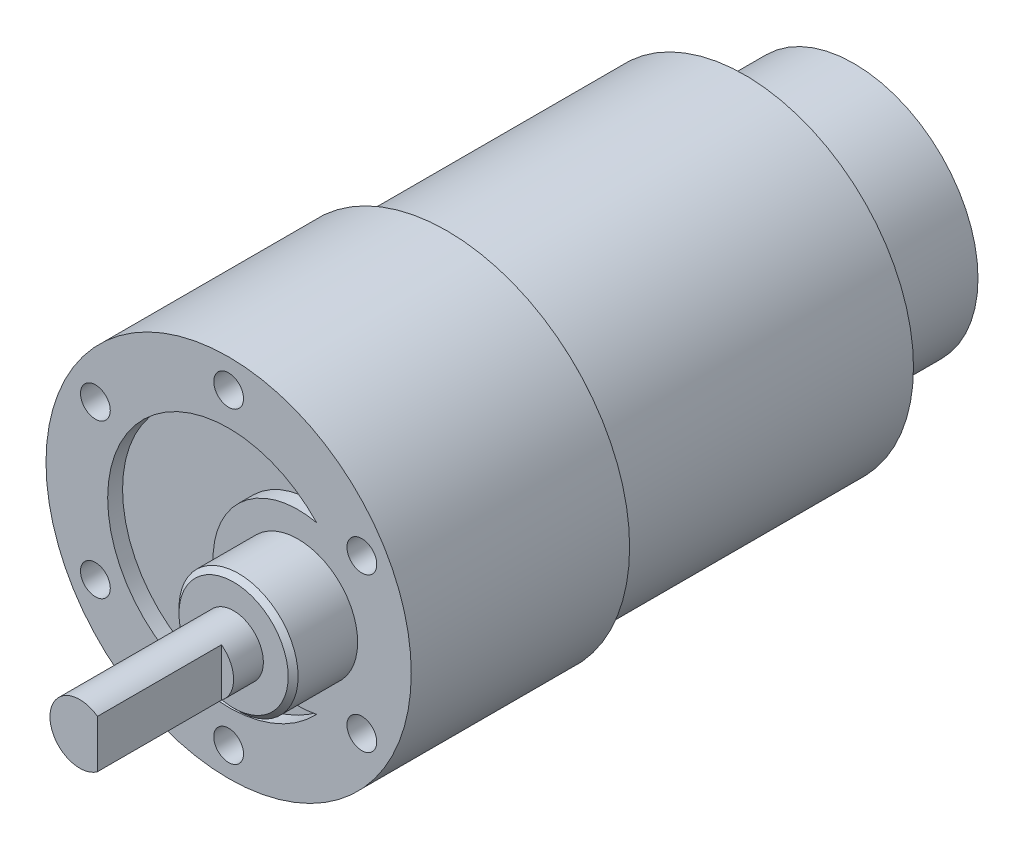
from build123d import *

# Parameters (mm, degrees)
SKETCH1_R           = 17
BOSS_EXTRUDE1_DEPTH = 30
FILLET1_R           = 1
SKETCH2_R           = 18.4
BOSS_EXTRUDE2_DEPTH = 22
SKETCH3_R           = 1.5
CUT_EXTRUDE1_DEPTH  = 3
SKETCH4_R           = 6
BOSS_EXTRUDE3_DEPTH = 6.5
CHAMFER1_SIZE       = 0.5
SKETCH5_R           = 3
BOSS_EXTRUDE4_DEPTH = 15.5
CUT_EXTRUDE3_DEPTH  = 1.5
SKETCH7_R           = 12.5
BOSS_EXTRUDE5_DEPTH = 11
CUT_EXTRUDE4_DEPTH  = 12.5


with BuildPart() as part:
    # Sketch1 → Boss-Extrude1 (new body)
    with BuildSketch(Plane.XY):
        Circle(SKETCH1_R)
    extrude(amount=BOSS_EXTRUDE1_DEPTH)

    # Fillet1
    fillet1_edges = [part.edges().sort_by_distance(p)[0] for p in [
        (-17, 0, 30),
    ]]
    fillet(fillet1_edges, radius=FILLET1_R)

    # Sketch2 → Boss-Extrude2 (add)
    with BuildSketch(Plane.XY.offset(30)):
        Circle(SKETCH2_R)
    extrude(amount=BOSS_EXTRUDE2_DEPTH)

    # Sketch3 → Cut-Extrude1 (cut)
    with BuildSketch(Plane.XY.offset(52)):
        with Locations((0, 15.5)):
            Circle(SKETCH3_R)
        with Locations((13.423393759, 7.75)):
            Circle(SKETCH3_R)
        with Locations((13.423393759, -7.75)):
            Circle(SKETCH3_R)
        with Locations((0, -15.5)):
            Circle(SKETCH3_R)
        with Locations((-13.423393759, -7.75)):
            Circle(SKETCH3_R)
        with Locations((-13.423393759, 7.75)):
            Circle(SKETCH3_R)
    extrude(amount=-CUT_EXTRUDE1_DEPTH, mode=Mode.SUBTRACT)

    # Sketch4 → Boss-Extrude3 (add)
    with BuildSketch(Plane.XY.offset(52)):
        with Locations((7, 0)):
            Circle(SKETCH4_R)
    extrude(amount=BOSS_EXTRUDE3_DEPTH)

    # Chamfer1
    chamfer1_edges = [part.edges().sort_by_distance(p)[0] for p in [
        (1, 0, 58.5),
    ]]
    chamfer(chamfer1_edges, length=CHAMFER1_SIZE)

    # Sketch5 → Boss-Extrude4 (add)
    with BuildSketch(Plane.XY.offset(58.5)):
        with Locations((7, 0)):
            Circle(SKETCH5_R)
    extrude(amount=BOSS_EXTRUDE4_DEPTH)

    # Sketch6 → Cut-Extrude3 (cut)
    with BuildSketch(Plane.XY.offset(52)):
        with BuildLine():
            ThreePointArc((8.868134735, -8.359715213), (-1.565907181, 0), (8.868134735, 8.359715213))
            ThreePointArc((8.868134735, 8.359715213), (-12.187233161, 0), (8.868134735, -8.359715213))
        make_face()
    extrude(amount=-CUT_EXTRUDE3_DEPTH, mode=Mode.SUBTRACT)

    # Sketch7 → Boss-Extrude5 (add)
    with BuildSketch(Plane(origin=(0, 0, 0), x_dir=(-1, 0, 0), z_dir=(0, 0, -1))):
        Circle(SKETCH7_R)
    extrude(amount=BOSS_EXTRUDE5_DEPTH)

    # Sketch8 → Cut-Extrude4 (cut)
    with BuildSketch(Plane.XY.offset(74)):
        with BuildLine():
            Line((8.779351905, 2.415348174), (8.779351905, -2.415348174))
            ThreePointArc((8.779351905, -2.415348174), (10, 0), (8.779351905, 2.415348174))
        make_face()
    extrude(amount=-CUT_EXTRUDE4_DEPTH, mode=Mode.SUBTRACT)


solid = part.part
